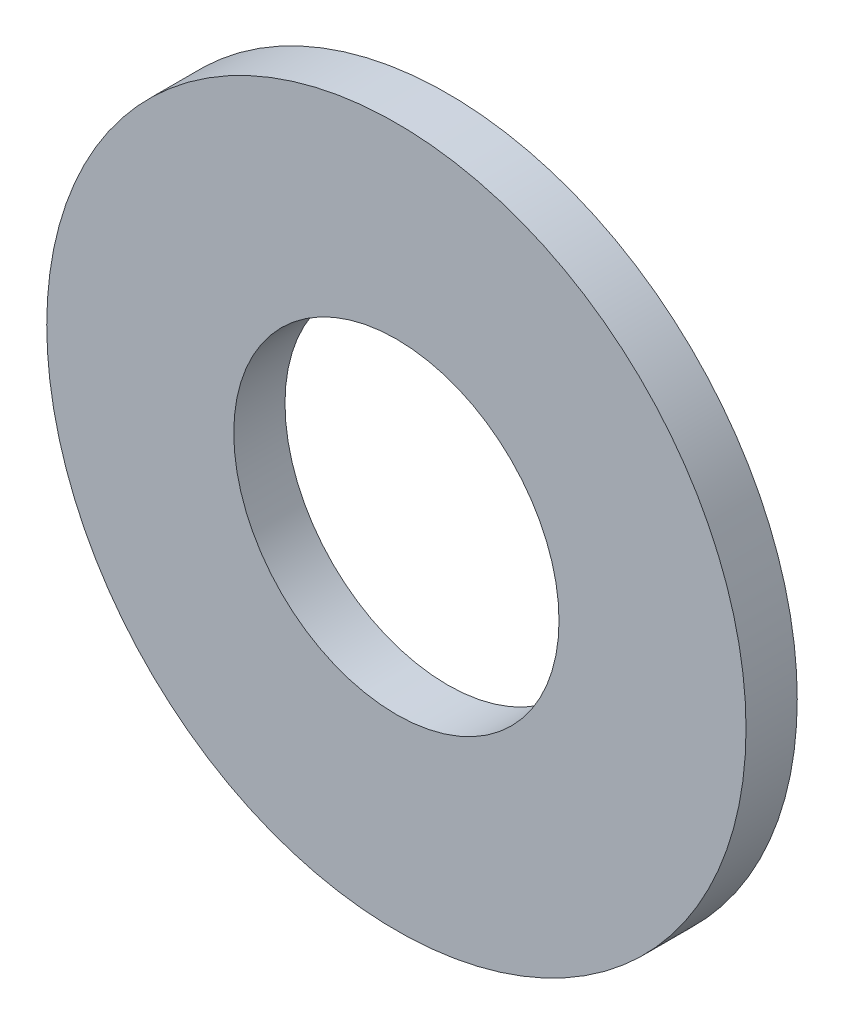
from build123d import *

# Parameters (mm, degrees)
SKETCH1_W = 0.8001
SKETCH1_H = 2.921


with BuildPart() as part:
    # Sketch1 → Revolve1 (revolve)
    with BuildSketch(Plane(origin=(0, 0, 0), x_dir=(0, 0, -1), z_dir=(1, 0, 0))):
        with Locations((0.40005, 4.0005)):
            Rectangle(SKETCH1_W, SKETCH1_H)
    revolve(axis=Axis((0, 0, 0), (0, 0, -1)))


solid = part.part
